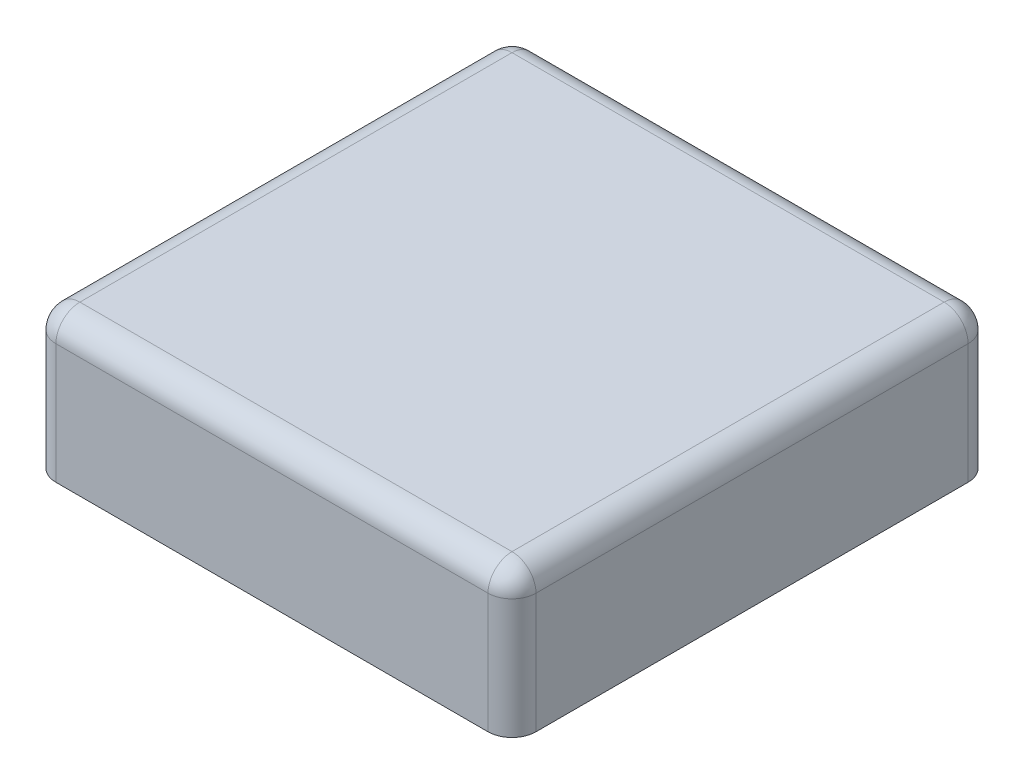
from build123d import *

# Parameters (mm, degrees)
SKETCH1_W             = 10
SKETCH1_H             = 10
BOSS_EXTRUDE2_DEPTH   = 3
SHELL2_T              = -0.7
FILLET2_R             = 0.5
BOSS_EXTRUDE3_DEPTH   = 2.5
BOSS_EXTRUDE3_2_DEPTH = 2.5
SKETCH6_W             = 0.8
SKETCH6_H             = 3.8
BOSS_EXTRUDE4_DEPTH   = 1
SKETCH7_W             = 1.5
SKETCH7_H             = 2.2
BOSS_EXTRUDE5_DEPTH   = 0.35
SKETCH9_W             = 1.8
SKETCH9_H             = 2.2
BOSS_EXTRUDE6_DEPTH   = 0.35


with BuildPart() as part:
    # Sketch1 → Boss-Extrude2 (new body)
    with BuildSketch(Plane(origin=(0, 0, 0), x_dir=(1, 0, 0), z_dir=(0, 1, 0))):
        Rectangle(SKETCH1_W, SKETCH1_H)
    extrude(amount=-BOSS_EXTRUDE2_DEPTH)

    # Shell2
    shell2_openings = [part.faces().sort_by_distance(p)[0] for p in [
        (0, -3, 0),
    ]]
    offset(amount=SHELL2_T, openings=shell2_openings, kind=Kind.INTERSECTION)

    # Fillet2
    fillet2_edges = [part.edges().sort_by_distance(p)[0] for p in [
        (0, 0, 5),
        (-5, 0, 0),
        (0, 0, -5),
        (5, 0, 0),
        (5, -1.5, 5),
        (-5, -1.5, 5),
        (-5, -1.5, -5),
        (5, -1.5, -5),
    ]]
    fillet(fillet2_edges, radius=FILLET2_R)

    # Sketch6 → Boss-Extrude4 (add, symmetric)
    with BuildSketch(Plane.XY):
        with Locations((2.3, -2.4)):
            Rectangle(SKETCH6_W, SKETCH6_H)
        with Locations((-2.3, -2.4)):
            Rectangle(SKETCH6_W, SKETCH6_H)
    extrude(amount=BOSS_EXTRUDE4_DEPTH, both=True)



with BuildPart() as body_2:
    # Sketch5 → Boss-Extrude3 (new body, symmetric)
    with BuildSketch(Plane(origin=(0, 0, 0), x_dir=(0, 0, -1), z_dir=(1, 0, 0))):
        Polygon((3, -0.5), (3, -4.5), (2.2, -4.5), (1.683643362, -3.605644068), (2.2, -2.711288136), (2.2, -0.5), align=None)
    extrude(amount=BOSS_EXTRUDE3_DEPTH, both=True)


with BuildPart() as body_3:
    # Sketch5 → Boss-Extrude3 2 (new body, symmetric)
    with BuildSketch(Plane(origin=(0, 0, 0), x_dir=(0, 0, -1), z_dir=(1, 0, 0))):
        Polygon((-2.2, -0.5), (-3, -0.5), (-3, -4.5), (-2.2, -4.5), (-1.683643362, -3.605644068), (-2.2, -2.711288136), align=None)
    extrude(amount=BOSS_EXTRUDE3_2_DEPTH, both=True)


with BuildPart() as part_1:
    add(part.part)

    add(body_2.part)  # Boss-Extrude5 merges body 2

    add(body_3.part)  # Boss-Extrude5 merges body 3
    # Sketch7 → Boss-Extrude5 (add, symmetric)
    with BuildSketch(Plane(origin=(0, 0, 0), x_dir=(0, 0, -1), z_dir=(1, 0, 0))):
        with Locations((-3.75, -1.6)):
            Rectangle(SKETCH7_W, SKETCH7_H)
        with Locations((3.75, -1.6)):
            Rectangle(SKETCH7_W, SKETCH7_H)
    extrude(amount=BOSS_EXTRUDE5_DEPTH, both=True)

    # Sketch9 → Boss-Extrude6 (add, symmetric)
    with BuildSketch(Plane.XY):
        with Locations((-3.6, -1.6)):
            Rectangle(SKETCH9_W, SKETCH9_H)
        with Locations((3.6, -1.6)):
            Rectangle(SKETCH9_W, SKETCH9_H)
    extrude(amount=BOSS_EXTRUDE6_DEPTH, both=True)


solid = part_1.part
